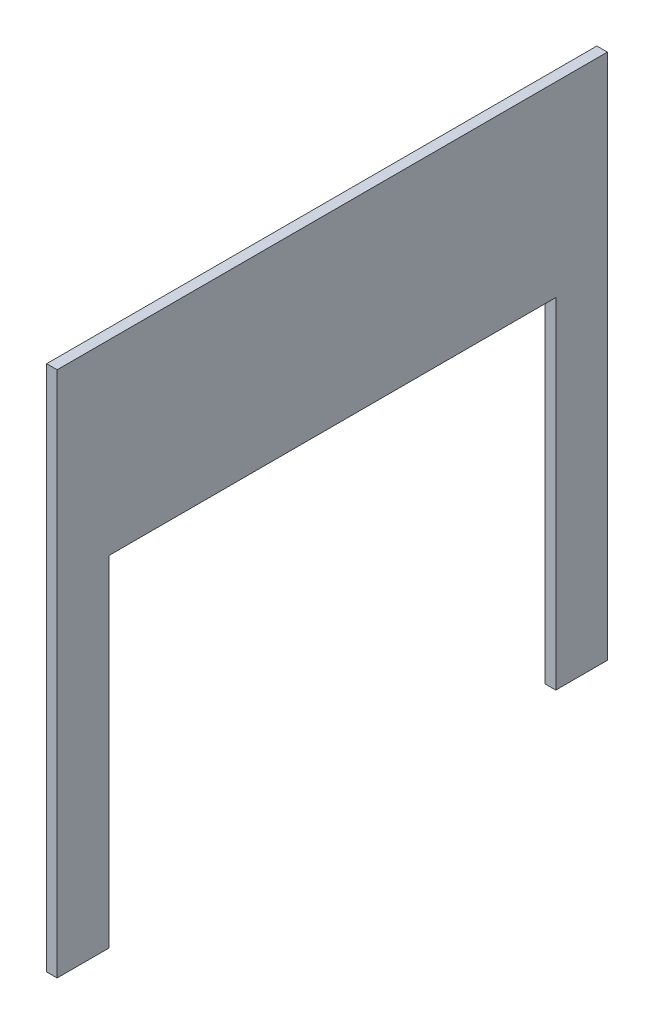
from build123d import *

# Parameters (mm, degrees)
SKETCH1_W           = 522.3
SKETCH1_H           = 500
BOSS_EXTRUDE1_DEPTH = 10
SKETCH2_W           = 424.3
SKETCH2_H           = 322.7
CUT_EXTRUDE1_DEPTH  = 10


with BuildPart() as part:
    # Sketch1 → Boss-Extrude1 (new body)
    with BuildSketch(Plane(origin=(0, 0, 0), x_dir=(0, 0, -1), z_dir=(1, 0, 0))):
        with Locations((261.15, 250)):
            Rectangle(SKETCH1_W, SKETCH1_H)
    extrude(amount=BOSS_EXTRUDE1_DEPTH)

    # Sketch2 → Cut-Extrude1 (cut)
    with BuildSketch(Plane.ZY):
        with Locations((-261.15, 161.35)):
            Rectangle(SKETCH2_W, SKETCH2_H)
    extrude(amount=-CUT_EXTRUDE1_DEPTH, mode=Mode.SUBTRACT)


solid = part.part
